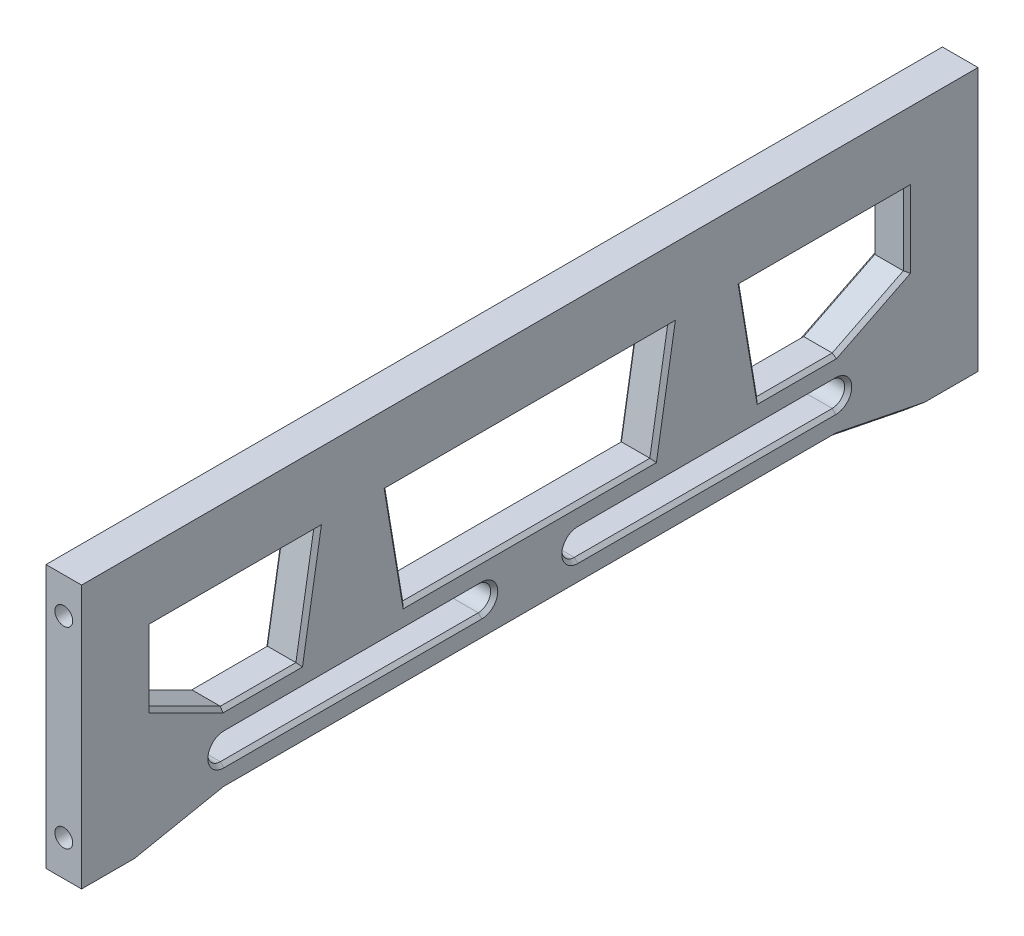
from build123d import *

# Parameters (mm, degrees)
CROQUIS1_W              = 5
CROQUIS1_H              = 10
SALIENTE_EXTRUIR1_DEPTH = 126
SALIENTE_EXTRUIR2_DEPTH = 5
CROQUIS2_R              = 1.25
CORTAR_EXTRUIR1_DEPTH   = 10
CROQUIS3_R              = 1.25
CORTAR_EXTRUIR2_DEPTH   = 10
CHAFL_N1_SIZE           = 0.5


with BuildPart() as part:
    # Croquis1 → Saliente-Extruir1 (new body)
    with BuildSketch(Plane.XY):
        Rectangle(CROQUIS1_W, CROQUIS1_H)
    extrude(amount=SALIENTE_EXTRUIR1_DEPTH)

    # Croquis4 → Saliente-Extruir2 (add)
    with BuildSketch(Plane.ZY.offset(2.5)):
        Polygon((0, -5), (0, -32), (10, -32), (20, -30), (106, -30), (116, -32), (126, -32), (126, -5), (116, -5), (116, -15), (106, -20), (95.375, -20), (92.875, -5), (82.875, -5), (80.375, -20), (45.625, -20), (43.125, -5), (33.125, -5), (30.625, -20), (20, -20), (10, -15), (10, -5), align=None)
        with BuildLine():
            Line((20, -23.25), (56.25, -23.25))
            ThreePointArc((56.25, -23.25), (58, -25), (56.25, -26.75))
            Line((56.25, -26.75), (20, -26.75))
            ThreePointArc((20, -26.75), (18.25, -25), (20, -23.25))
        make_face(mode=Mode.SUBTRACT)
        with BuildLine():
            Line((69.75, -23.25), (106, -23.25))
            ThreePointArc((106, -23.25), (107.75, -25), (106, -26.75))
            Line((106, -26.75), (69.75, -26.75))
            ThreePointArc((69.75, -26.75), (68, -25), (69.75, -23.25))
        make_face(mode=Mode.SUBTRACT)
    extrude(amount=-SALIENTE_EXTRUIR2_DEPTH)

    # Croquis2 → Cortar-Extruir1 (cut)
    with BuildSketch(Plane.XY.offset(126)):
        Circle(CROQUIS2_R)
        with Locations((0, -27)):
            Circle(CROQUIS2_R)
    extrude(amount=-CORTAR_EXTRUIR1_DEPTH, mode=Mode.SUBTRACT)

    # Croquis3 → Cortar-Extruir2 (cut)
    with BuildSketch(Plane(origin=(0, 0, 0), x_dir=(-1, 0, 0), z_dir=(0, 0, -1))):
        Circle(CROQUIS3_R)
        with Locations((0, -27)):
            Circle(CROQUIS3_R)
    extrude(amount=-CORTAR_EXTRUIR2_DEPTH, mode=Mode.SUBTRACT)

    # Chaflán1
    chafl_n1_edges = [part.edges().sort_by_distance(p)[0] for p in [
        (2.5, -5, 104.4375),
        (2.5, -5, 63),
        (2.5, -5, 21.5625),
        (-2.5, -5, 104.4375),
        (-2.5, -5, 63),
        (-2.5, -5, 21.5625),
        (2.5, -10, 10),
        (2.5, -17.5, 15),
        (2.5, -20, 25.3125),
        (2.5, -12.5, 31.875),
        (2.5, -12.5, 44.375),
        (2.5, -20, 63),
        (2.5, -12.5, 81.625),
        (2.5, -12.5, 94.125),
        (2.5, -20, 100.6875),
        (2.5, -17.5, 111),
        (2.5, -10, 116),
        (2.5, -31, 111),
        (2.5, -30, 63),
        (2.5, -31, 15),
        (2.5, -25, 18.25),
        (2.5, -26.75, 38.125),
        (2.5, -25, 58),
        (2.5, -23.25, 38.125),
        (2.5, -25, 68),
        (2.5, -26.75, 87.875),
        (2.5, -25, 107.75),
        (2.5, -23.25, 87.875),
        (-2.5, -31, 15),
        (-2.5, -30, 63),
        (-2.5, -31, 111),
        (-2.5, -10, 116),
        (-2.5, -17.5, 111),
        (-2.5, -20, 100.6875),
        (-2.5, -12.5, 94.125),
        (-2.5, -12.5, 81.625),
        (-2.5, -20, 63),
        (-2.5, -12.5, 44.375),
        (-2.5, -12.5, 31.875),
        (-2.5, -20, 25.3125),
        (-2.5, -17.5, 15),
        (-2.5, -10, 10),
        (-2.5, -25, 68),
        (-2.5, -23.25, 87.875),
        (-2.5, -25, 107.75),
        (-2.5, -26.75, 87.875),
        (-2.5, -25, 18.25),
        (-2.5, -23.25, 38.125),
        (-2.5, -25, 58),
        (-2.5, -26.75, 38.125),
    ]]
    chamfer(chafl_n1_edges, length=CHAFL_N1_SIZE)


solid = part.part
